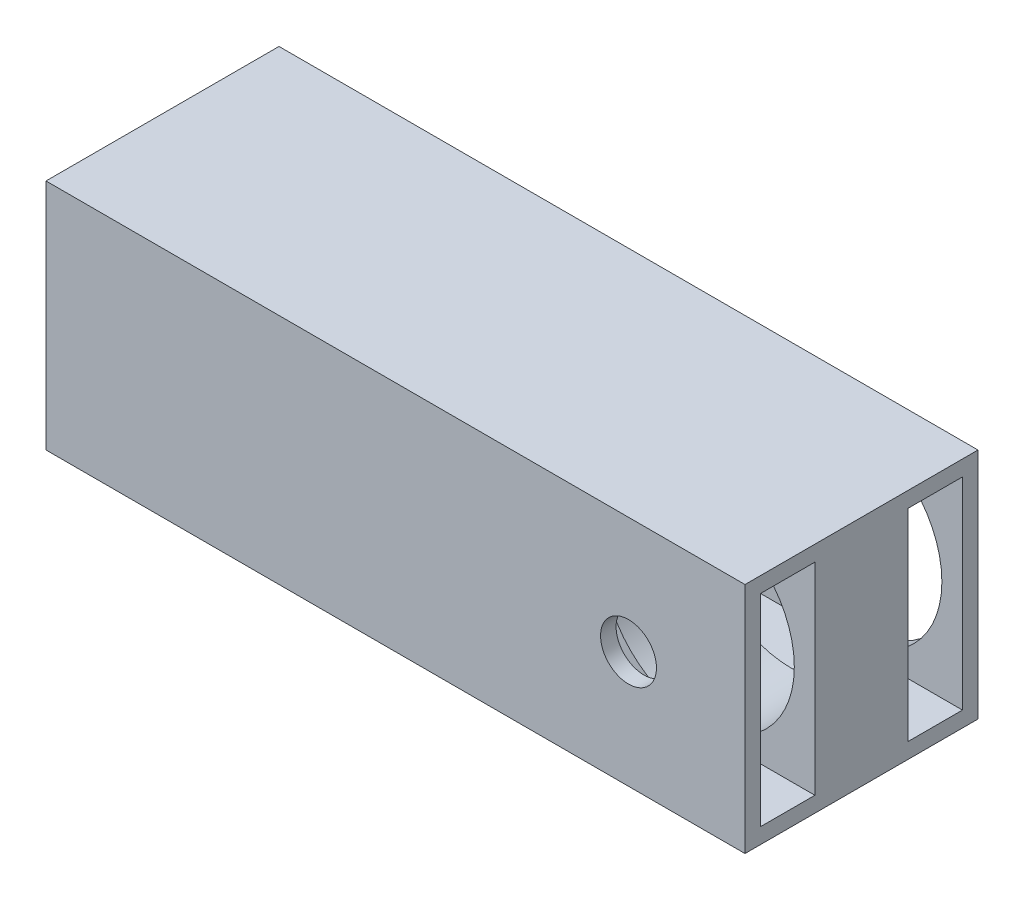
from build123d import *

# Parameters (mm, degrees)
SKETCH1_W           = 30
SKETCH1_H           = 30
SKETCH1_W_2         = 7
SKETCH1_H_2         = 26
BOSS_EXTRUDE3_DEPTH = 90
SKETCH6_R           = 12.35
CUT_EXTRUDE5_DEPTH  = 23
SKETCH8_R           = 3.6
CUT_EXTRUDE6_DEPTH  = 17


with BuildPart() as part:
    # Sketch1 → Boss-Extrude3 (new body)
    with BuildSketch(Plane(origin=(0, 0, 0), x_dir=(0, 0, -1), z_dir=(1, 0, 0))):
        Rectangle(SKETCH1_W, SKETCH1_H)
        with Locations((-9.5, 0)):
            Rectangle(SKETCH1_W_2, SKETCH1_H_2, mode=Mode.SUBTRACT)
        with Locations((9.5, 0)):
            Rectangle(SKETCH1_W_2, SKETCH1_H_2, mode=Mode.SUBTRACT)
    extrude(amount=BOSS_EXTRUDE3_DEPTH)

    # Sketch6 → Cut-Extrude5 (cut)
    with BuildSketch(Plane(origin=(0, 0, -15), x_dir=(-1, 0, 0), z_dir=(0, 0, -1))):
        with Locations((-75, 0)):
            Circle(SKETCH6_R)
    extrude(amount=-CUT_EXTRUDE5_DEPTH, mode=Mode.SUBTRACT)

    # Sketch8 → Cut-Extrude6 (cut)
    with BuildSketch(Plane.XY.offset(15)):
        with Locations((75, 0)):
            Circle(SKETCH8_R)
    extrude(amount=-CUT_EXTRUDE6_DEPTH, mode=Mode.SUBTRACT)


solid = part.part
